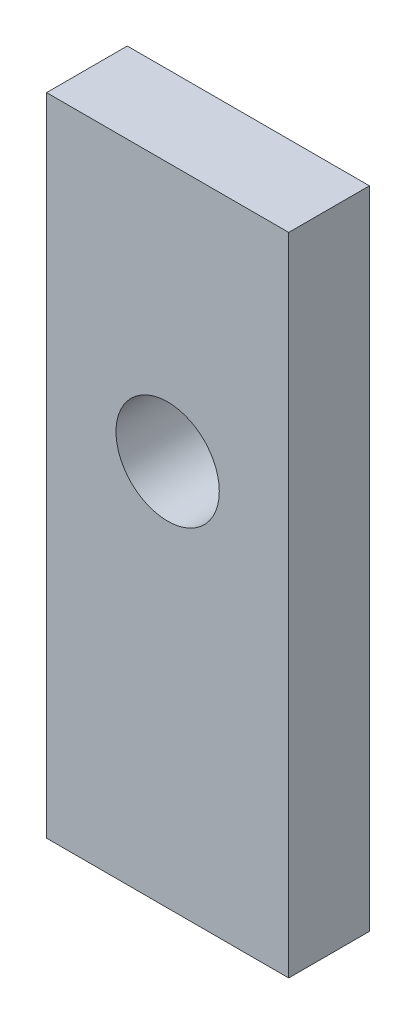
from build123d import *

# Parameters (mm, degrees)
SKETCH1_W           = 15
SKETCH1_H           = 40
SKETCH1_R           = 3.2
BOSS_EXTRUDE1_DEPTH = 2.5


with BuildPart() as part:
    # Sketch1 → Boss-Extrude1 (new body, symmetric)
    with BuildSketch(Plane.XY):
        Rectangle(SKETCH1_W, SKETCH1_H)
        with Locations((0, 3.9595)):
            Circle(SKETCH1_R, mode=Mode.SUBTRACT)
    extrude(amount=BOSS_EXTRUDE1_DEPTH, both=True)


solid = part.part
